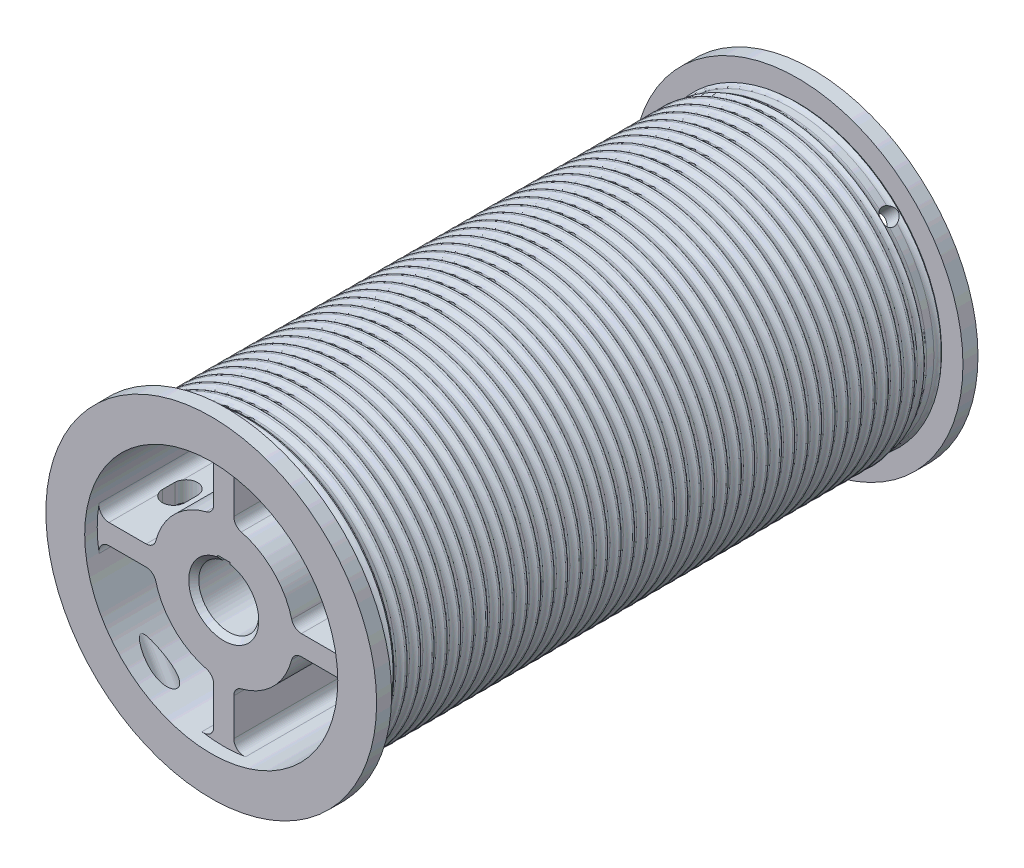
from build123d import *

# Parameters (mm, degrees)
SKETCH1_R          = 90.678
SKETCH1_R_2        = 12.7
EXTRUDE1_DEPTH     = 381
SKETCH2_R          = 104.775
SKETCH2_R_2        = 90.678
EXTRUDE2_DEPTH     = 9.525
SKETCH3_R          = 104.775
SKETCH3_R_2        = 90.678
EXTRUDE4_DEPTH     = 9.525
CUT_EXTRUDE1_DEPTH = 63.5
SKETCH5_R          = 80.16875
CUT_EXTRUDE2_DEPTH = 7.9375
SKETCH6_R          = 80.16875
CUT_EXTRUDE3_DEPTH = 7.9375
LPATTERN1_COUNT    = 43
LPATTERN1_PITCH    = 8.466666658
SKETCH12_R         = 5.55625
CUT_EXTRUDE5_DEPTH = 143.785196552
SKETCH18_R         = 5.159375
CUT_EXTRUDE6_DEPTH = 25.4
CUT_EXTRUDE7_START = -6.446121
CUT_EXTRUDE7_DEPTH = 12.892242
SKETCH21_R         = 17.48155
CUT_EXTRUDE8_DEPTH = 85.725
CHAMFER1_SIZE      = 3.175


with BuildPart() as part:
    # Sketch1 → Extrude1 (new body)
    with BuildSketch(Plane.XY):
        Circle(SKETCH1_R)
        Circle(SKETCH1_R_2, mode=Mode.SUBTRACT)
        with BuildLine():
            Line((6.35, -49.186888497), (6.35, -72.718071011))
            ThreePointArc((6.35, -72.718071011), (8.614336302, -77.579125645), (13.792473118, -78.973388947))
            ThreePointArc((13.792473118, -78.973388947), (56.687866764, -56.687866764), (78.973388947, -13.792473118))
            ThreePointArc((78.973388947, -13.792473118), (77.579125645, -8.614336302), (72.718071011, -6.35))
            Line((72.718071011, -6.35), (49.186888497, -6.35))
            ThreePointArc((49.186888497, -6.35), (45.29832353, -7.679884214), (43.038527435, -11.1125))
            ThreePointArc((43.038527435, -11.1125), (31.430896424, -31.430896424), (11.1125, -43.038527435))
            ThreePointArc((11.1125, -43.038527435), (7.679884214, -45.29832353), (6.35, -49.186888497))
        make_face(mode=Mode.SUBTRACT)
        with BuildLine():
            Line((-6.35, -49.186888497), (-6.35, -72.718071011))
            ThreePointArc((-6.35, -72.718071011), (-8.614336302, -77.579125645), (-13.792473118, -78.973388947))
            ThreePointArc((-13.792473118, -78.973388947), (-56.687866764, -56.687866764), (-78.973388947, -13.792473118))
            ThreePointArc((-78.973388947, -13.792473118), (-77.579125645, -8.614336302), (-72.718071011, -6.35))
            Line((-72.718071011, -6.35), (-49.186888497, -6.35))
            ThreePointArc((-49.186888497, -6.35), (-45.29832353, -7.679884214), (-43.038527435, -11.1125))
            ThreePointArc((-43.038527435, -11.1125), (-31.430896424, -31.430896424), (-11.1125, -43.038527435))
            ThreePointArc((-11.1125, -43.038527435), (-7.679884214, -45.29832353), (-6.35, -49.186888497))
        make_face(mode=Mode.SUBTRACT)
        with BuildLine():
            Line((-49.186888497, 6.35), (-72.718071011, 6.35))
            ThreePointArc((-72.718071011, 6.35), (-77.579125645, 8.614336302), (-78.973388947, 13.792473118))
            ThreePointArc((-78.973388947, 13.792473118), (-56.687866764, 56.687866764), (-13.792473118, 78.973388947))
            ThreePointArc((-13.792473118, 78.973388947), (-8.614336302, 77.579125645), (-6.35, 72.718071011))
            Line((-6.35, 72.718071011), (-6.35, 49.186888497))
            ThreePointArc((-6.35, 49.186888497), (-7.679884214, 45.29832353), (-11.1125, 43.038527435))
            ThreePointArc((-11.1125, 43.038527435), (-31.430896424, 31.430896424), (-43.038527435, 11.1125))
            ThreePointArc((-43.038527435, 11.1125), (-45.29832353, 7.679884214), (-49.186888497, 6.35))
        make_face(mode=Mode.SUBTRACT)
        with BuildLine():
            Line((6.35, 49.186888497), (6.35, 72.718071011))
            ThreePointArc((6.35, 72.718071011), (8.614336302, 77.579125645), (13.792473118, 78.973388947))
            ThreePointArc((13.792473118, 78.973388947), (56.687866764, 56.687866764), (78.973388947, 13.792473118))
            ThreePointArc((78.973388947, 13.792473118), (77.579125645, 8.614336302), (72.718071011, 6.35))
            Line((72.718071011, 6.35), (49.186888497, 6.35))
            ThreePointArc((49.186888497, 6.35), (45.29832353, 7.679884214), (43.038527435, 11.1125))
            ThreePointArc((43.038527435, 11.1125), (31.430896424, 31.430896424), (11.1125, 43.038527435))
            ThreePointArc((11.1125, 43.038527435), (7.679884214, 45.29832353), (6.35, 49.186888497))
        make_face(mode=Mode.SUBTRACT)
    extrude(amount=-EXTRUDE1_DEPTH)

    # Sketch2 → Extrude2 (add)
    with BuildSketch(Plane.XY):
        Circle(SKETCH2_R)
        Circle(SKETCH2_R_2, mode=Mode.SUBTRACT)
    extrude(amount=-EXTRUDE2_DEPTH)

    # Sketch3 → Extrude4 (add)
    with BuildSketch(Plane.XY.offset(-381)):
        Circle(SKETCH3_R)
        Circle(SKETCH3_R_2, mode=Mode.SUBTRACT)
    extrude(amount=EXTRUDE4_DEPTH)

    # Sketch4 → Cut-Extrude1 (cut)
    with BuildSketch(Plane.XY):
        with BuildLine():
            Line((3.96875, 22.806705782), (-3.96875, 22.806705782))
            Line((-3.96875, 22.806705782), (-3.96875, 18.583955782))
            ThreePointArc((-3.96875, 18.583955782), (0, -19.00301), (3.96875, 18.583955782))
            Line((3.96875, 18.583955782), (3.96875, 22.806705782))
        make_face()
    extrude(amount=-CUT_EXTRUDE1_DEPTH, mode=Mode.SUBTRACT)

    # Sketch5 → Cut-Extrude2 (cut)
    with BuildSketch(Plane.XY):
        Circle(SKETCH5_R)
    extrude(amount=-CUT_EXTRUDE2_DEPTH, mode=Mode.SUBTRACT)

    # Sketch6 → Cut-Extrude3 (cut)
    with BuildSketch(Plane.XY.offset(-381)):
        Circle(SKETCH6_R)
    extrude(amount=CUT_EXTRUDE3_DEPTH, mode=Mode.SUBTRACT)

    # Sketch8 → Revolve1 (revolve)
    with BuildSketch(Plane(origin=(0, 0, 0), x_dir=(0, 0, -1), z_dir=(1, 0, 0)), mode=Mode.PRIVATE) as revolve1_sk:
        with BuildLine():
            Line((17.9832, 90.678), (9.525, 90.678))
            ThreePointArc((9.525, 90.678), (11.628143136, 91.264517441), (13.124234043, 92.854777091))
            ThreePointArc((13.124234043, 92.854777091), (13.7541, 93.235713082), (14.383965957, 92.854777091))
            ThreePointArc((14.383965957, 92.854777091), (15.880056864, 91.264517441), (17.9832, 90.678))
        make_face()
    revolve1 = revolve(revolve1_sk.sketch.rotate(Axis((0, 0, -9.525), (0, 0, 1)), 270), axis=Axis((0, 0, -9.525), (0, 0, 1)))  # turned: the seam where the file's is

    # LPattern1: Revolve1 ×43
    with Locations(*[(0, 0, -i * LPATTERN1_PITCH) for i in range(1, LPATTERN1_COUNT)]):
        add(revolve1)

    # Sketch9 → Cut-Revolve1 (revolve, cut)
    with BuildSketch(Plane(origin=(0, 0, 0), x_dir=(0, 0, -1), z_dir=(1, 0, 0)), mode=Mode.PRIVATE) as cut_revolve1_sk:
        with BuildLine():
            Line((13.589, 90.424), (18.161, 90.424))
            ThreePointArc((18.161, 90.424), (21.034681959, 91.614318041), (22.225, 94.488))
            Line((22.225, 94.488), (22.225, 95.1865))
            Line((22.225, 95.1865), (9.525, 95.1865))
            Line((9.525, 95.1865), (9.525, 94.488))
            ThreePointArc((9.525, 94.488), (10.715318041, 91.614318041), (13.589, 90.424))
        make_face()
    revolve(cut_revolve1_sk.sketch.rotate(Axis((0, 0, -9.525), (0, 0, 1)), 90), axis=Axis((0, 0, -9.525), (0, 0, 1)), mode=Mode.SUBTRACT)  # turned: the seam where the file's is

    # Sketch11 → Cut-Revolve2 (revolve, cut)
    with BuildSketch(Plane(origin=(0, 0, 0), x_dir=(0, 0, -1), z_dir=(1, 0, 0)), mode=Mode.PRIVATE) as cut_revolve2_sk:
        with BuildLine():
            Line((367.411, 90.424), (362.839, 90.424))
            ThreePointArc((362.839, 90.424), (359.965318041, 91.614318041), (358.775, 94.488))
            Line((358.775, 94.488), (358.775, 95.1865))
            Line((358.775, 95.1865), (371.475, 95.1865))
            Line((371.475, 95.1865), (371.475, 94.488))
            ThreePointArc((371.475, 94.488), (370.284681959, 91.614318041), (367.411, 90.424))
        make_face()
    revolve(cut_revolve2_sk.sketch.rotate(Axis((0, 0, -9.525), (0, 0, 1)), 90), axis=Axis((0, 0, -9.525), (0, 0, 1)), mode=Mode.SUBTRACT)  # turned: the seam where the file's is

    # Sketch12 → Cut-Extrude5 (cut, through all)
    with BuildSketch(Plane(origin=(0, 0, 0), x_dir=(-0.870355696, -0.49242356, 0), z_dir=(-0.49242356, 0.870355696, 0))):
        with Locations((73.025, -15.875)):
            Circle(SKETCH12_R)
    extrude(amount=-CUT_EXTRUDE5_DEPTH, mode=Mode.SUBTRACT)

    # Sketch13 → 3/8-16 Tapped Hole1 (revolve, cut)
    with BuildSketch(Plane(origin=(0, 0, -365.125), x_dir=(0.707106781, -0.707106781, 0), z_dir=(0, 0, 1))):
        Polygon((0, 0), (0, 100.809665582), (3.96875, 98.425), (3.96875, 0), align=None)
    revolve(axis=Axis((-4.490128061, -4.490128061, -365.125), (0.707106781, 0.707106781, 0)), mode=Mode.SUBTRACT)

    # Sketch18 → Cut-Extrude6 (cut)
    with BuildSketch(Plane(origin=(71.842048969, 71.842048969, 0), x_dir=(0, 0, -1), z_dir=(0.707106781, 0.707106781, 0))):
        with Locations(Location((365.125, 0, 0), (0, 0, 90))):  # turned: the seam where the file's is
            Circle(SKETCH18_R)
    extrude(amount=-CUT_EXTRUDE6_DEPTH, mode=Mode.SUBTRACT)

    # Sketch19 → Cut-Extrude7 (cut)
    with BuildSketch(Plane(origin=(0, 0, 0), x_dir=(-1, 0, 0), z_dir=(0, 1, 0)).offset(CUT_EXTRUDE7_START)):
        with BuildLine():
            Line((-59.53125, -330.2), (-59.53125, -338.1375))
            ThreePointArc((-59.53125, -338.1375), (-66.675, -345.28125), (-73.81875, -338.1375))
            Line((-73.81875, -338.1375), (-73.81875, -330.2))
            ThreePointArc((-73.81875, -330.2), (-66.675, -323.05625), (-59.53125, -330.2))
        make_face()
        with BuildLine():
            Line((-59.53125, -42.8625), (-59.53125, -50.8))
            ThreePointArc((-59.53125, -50.8), (-66.675, -57.94375), (-73.81875, -50.8))
            Line((-73.81875, -50.8), (-73.81875, -42.8625))
            ThreePointArc((-73.81875, -42.8625), (-66.675, -35.71875), (-59.53125, -42.8625))
        make_face()
    cut_extrude7 = extrude(amount=CUT_EXTRUDE7_DEPTH, mode=Mode.SUBTRACT)

    # Mirror1: Cut-Extrude7 across plane
    add(cut_extrude7.mirror(Plane(origin=(0, 0, 0), x_dir=(0, 0, 1), z_dir=(1, 0, 0))), mode=Mode.SUBTRACT)

    # Sketch20 → Cut-Revolve3 (revolve, cut)
    with BuildSketch(Plane(origin=(0, 0, 0), x_dir=(0, 0, -1), z_dir=(1, 0, 0)), mode=Mode.PRIVATE) as cut_revolve3_sk:
        with BuildLine():
            Line((66.675, 0), (66.675, 34.925))
            Line((66.675, 34.925), (142.62221575, 64.135467596))
            ThreePointArc((142.62221575, 64.135467596), (149.343882504, 66.034737155), (156.299318672, 66.675))
            Line((156.299318672, 66.675), (224.700681328, 66.675))
            ThreePointArc((224.700681328, 66.675), (231.656117496, 66.034737155), (238.37778425, 64.135467596))
            Line((238.37778425, 64.135467596), (314.325, 34.925))
            Line((314.325, 34.925), (314.325, 0))
            Line((314.325, 0), (66.675, 0))
        make_face()
    revolve(cut_revolve3_sk.sketch.rotate(Axis((0, 0, -637.476114818), (0, 0, 1)), 90), axis=Axis((0, 0, -637.476114818), (0, 0, 1)), mode=Mode.SUBTRACT)  # turned: the seam where the file's is

    # Sketch21 → Cut-Extrude8 (cut)
    with BuildSketch(Plane(origin=(0, 0, -373.0625), x_dir=(-1, 0, 0), z_dir=(0, 0, -1))):
        Circle(SKETCH21_R)
    extrude(amount=-CUT_EXTRUDE8_DEPTH, mode=Mode.SUBTRACT)

    # Chamfer1
    chamfer1_edges = [part.edges().sort_by_distance(p)[0] for p in [
        (0, -19.00301, -7.9375),
        (17.48155, 0, -373.0625),
    ]]
    chamfer(chamfer1_edges, length=CHAMFER1_SIZE)


solid = part.part
